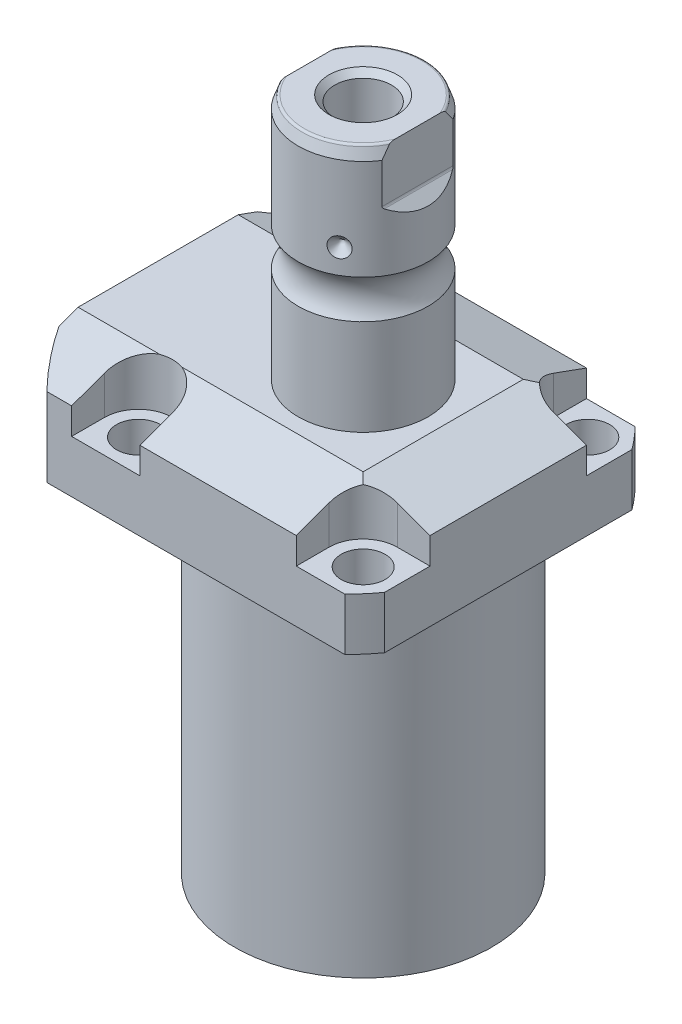
from build123d import *

# Parameters (mm, degrees)
SKETCH1_W                = 70.866
SKETCH1_H                = 85.496
EXTRUDE1_DEPTH           = 104.4448
SKETCH2_OUTSIDE_W        = 117.986
SKETCH2_OUTSIDE_H        = 103.356
SKETCH2_OUTSIDE_R        = 50.8
CUT_EXTRUDE1_DEPTH       = 105.4448
SKETCH3_W                = 45.1992
SKETCH3_H                = 79.4258
FILLET1_R                = 0.381
CUT_EXTRUDE2_DEPTH       = 12.243
CUT_EXTRUDE9_START       = -51.063
CUT_EXTRUDE9_DEPTH       = 87.496
CUT_EXTRUDE7_DEPTH       = 36.433
CUT_EXTRUDE7_DEPTH_BACK  = 36.433
SKETCH10_R               = 1.1811
SKETCH17_W               = 5.3594
SKETCH17_H               = 12.776
HOLE1_AT_2_COUNT         = 2
HOLE1_AT_2_PITCH         = 54.864
HOLE1_AT_3_COUNT         = 2
HOLE1_AT_3_PITCH         = 77.589412886
HOLE1_AT_4_COUNT         = 2
HOLE1_AT_4_PITCH         = 54.864
CHAMFER1_SIZE            = 0.635
FILLET2_R                = 0.635
CIRPATTERN1_COUNT        = 3
CUT_EXTRUDE10_DEPTH      = 36.433
CUT_EXTRUDE10_DEPTH_BACK = 36.433
CHAMFER2_SIZE            = 1.4351


with BuildPart() as part:
    # Sketch1 → Extrude1 (new body)
    with BuildSketch(Plane(origin=(0, 0, 0), x_dir=(0, 0, 1), z_dir=(0, -1, 0))):
        with Locations((0, 7.315)):
            Rectangle(SKETCH1_W, SKETCH1_H)
    extrude(amount=-EXTRUDE1_DEPTH)

    # Sketch2 outside → Cut-Extrude1 (cut, through all)
    with BuildSketch(Plane.XZ):
        with Locations((-7.315, 0)):
            Rectangle(SKETCH2_OUTSIDE_W, SKETCH2_OUTSIDE_H)
        with Locations((-5.4102, 0)):
            Circle(SKETCH2_OUTSIDE_R, mode=Mode.SUBTRACT)
    extrude(amount=-CUT_EXTRUDE1_DEPTH, mode=Mode.SUBTRACT)

    # Sketch3 → Cut-Revolve1 (revolve, cut)
    with BuildSketch(Plane(origin=(0, 0, 0), x_dir=(0, 0, -1), z_dir=(1, 0, 0))):
        with Locations((53.9941, 39.7129)):
            Rectangle(SKETCH3_W, SKETCH3_H)
    revolve(axis=Axis((0, -93.345, 0), (0, 1, 0)), mode=Mode.SUBTRACT)

    # Fillet1
    fillet1_edges = [part.edges().sort_by_distance(p)[0] for p in [
        (0, 79.4258, 31.3945),
    ]]
    fillet(fillet1_edges, radius=FILLET1_R)

    # Sketch4 → Cut-Extrude2 (cut)
    with BuildSketch(Plane(origin=(0, 104.4448, 0), x_dir=(-1, 0, 0), z_dir=(0, 1, 0))):
        with BuildLine():
            Line((-19.1008, -35.433), (-19.1008, -27.432))
            ThreePointArc((-19.1008, -27.432), (-21.540951985, -21.540951985), (-27.432, -19.1008))
            Line((-27.432, -19.1008), (-35.433, -19.1008))
            Line((-35.433, -19.1008), (-35.433, -35.433))
            Line((-35.433, -35.433), (-19.1008, -35.433))
        make_face()
        with BuildLine():
            Line((35.7632, -35.433), (19.1008, -35.433))
            Line((19.1008, -35.433), (19.1008, -27.432))
            ThreePointArc((19.1008, -27.432), (27.432, -19.1008), (35.7632, -27.432))
            Line((35.7632, -27.432), (35.7632, -35.433))
        make_face()
        with BuildLine():
            Line((19.1008, 35.433), (19.1008, 27.432))
            ThreePointArc((19.1008, 27.432), (27.432, 19.1008), (35.7632, 27.432))
            Line((35.7632, 27.432), (35.7632, 35.433))
            Line((35.7632, 35.433), (19.1008, 35.433))
        make_face()
        with BuildLine():
            Line((-27.432, 19.1008), (-35.433, 19.1008))
            Line((-35.433, 19.1008), (-35.433, 35.433))
            Line((-35.433, 35.433), (-19.1008, 35.433))
            Line((-19.1008, 35.433), (-19.1008, 27.432))
            ThreePointArc((-19.1008, 27.432), (-21.540951985, 21.540951985), (-27.432, 19.1008))
        make_face()
    extrude(amount=-CUT_EXTRUDE2_DEPTH, mode=Mode.SUBTRACT)

    # Sketch5 → Cut-Extrude9 (cut)
    with BuildSketch(Plane(origin=(0, 0, 0), x_dir=(0, 0, -1), z_dir=(1, 0, 0)).offset(CUT_EXTRUDE9_START)):
        Polygon((-19.558, 104.4448), (-35.433, 98.666772531), (-35.433, 104.4448), align=None)
    cut_extrude9 = extrude(amount=CUT_EXTRUDE9_DEPTH, mode=Mode.SUBTRACT)

    # Mirror1: Cut-Extrude9 across plane
    add(cut_extrude9.mirror(Plane.XY), mode=Mode.SUBTRACT)

    # Sketch9 → Cut-Extrude7 (cut, two sides)
    with BuildSketch(Plane.XY) as cut_extrude7_sk:
        Polygon((19.558, 104.4448), (35.433, 98.666772531), (35.433, 104.4448), align=None)
    extrude(amount=CUT_EXTRUDE7_DEPTH, mode=Mode.SUBTRACT)
    extrude(cut_extrude7_sk.sketch, amount=-CUT_EXTRUDE7_DEPTH_BACK, mode=Mode.SUBTRACT)

    # Sketch20 → Cut-Revolve4 (revolve, cut)
    with BuildSketch(Plane(origin=(-35.0774, 88.9, -18.1102), x_dir=(0, 1, 0), z_dir=(1, 0, 0)), mode=Mode.PRIVATE) as cut_revolve4_sk:
        Polygon((-9.4742, 38.3413), (-8.0264, 38.3413), (-8.0264, 35.8902), (-7.0104, 35.8902), (-7.0104, 33.8836), (3.9624, 33.8836), (3.9624, 32.639), (-9.4742, 32.639), align=None)
    cut_revolve4 = revolve(cut_revolve4_sk.sketch.rotate(Axis((-35.0774, 81.620304954, 14.5288), (0, 1, 0)), 180), axis=Axis((-35.0774, 81.620304954, 14.5288), (0, 1, 0)), mode=Mode.SUBTRACT)  # turned: the seam where the file's is

    # Mirror10: Cut-Revolve4 across plane
    add(cut_revolve4.mirror(Plane.XY), mode=Mode.SUBTRACT)

    # Sketch15 → Revolve3 (revolve)
    with BuildSketch(Plane(origin=(0, 0, 0), x_dir=(0, 0, -1), z_dir=(1, 0, 0)), mode=Mode.PRIVATE) as revolve3_sk:
        with BuildLine():
            Line((0, 104.4448), (15.875, 104.4448))
            Line((15.875, 104.4448), (15.875, 127.82970643))
            ThreePointArc((15.875, 127.82970643), (14.3256, 132.5368), (15.875, 137.24389357))
            Line((15.875, 137.24389357), (15.875, 161.72179416))
            Line((15.875, 161.72179416), (14.81184082, 164.6428))
            Line((14.81184082, 164.6428), (0, 164.6428))
            Line((0, 164.6428), (0, 104.4448))
        make_face()
    revolve(revolve3_sk.sketch.rotate(Axis((0, 250.290824608, 0), (0, -1, 0)), 180), axis=Axis((0, 250.290824608, 0), (0, -1, 0)))  # turned: the seam where the file's is

    # Sketch17 → Hole1 (revolve, cut)
    with BuildSketch(Plane(origin=(27.432, 92.2018, -27.432), x_dir=(0, 0, 1), z_dir=(1, 0, 0))):
        with Locations((2.6797, 6.388)):
            Rectangle(SKETCH17_W, SKETCH17_H)
    hole1 = revolve(axis=Axis((27.432, -17.7982, -27.432), (0, 1, 0)), mode=Mode.SUBTRACT)

    # Hole1 at 2: Hole1 ×2
    with Locations(*[(0, 0, i * HOLE1_AT_2_PITCH) for i in range(1, HOLE1_AT_2_COUNT)]):
        add(hole1, mode=Mode.SUBTRACT)

    # Hole1 at 3: Hole1 ×2
    with Locations(*[Vector(-0.707106781, 0, 0.707106781) * (i * HOLE1_AT_3_PITCH) for i in range(1, HOLE1_AT_3_COUNT)]):
        add(hole1, mode=Mode.SUBTRACT)

    # Hole1 at 4: Hole1 ×2
    with Locations(*[(-i * HOLE1_AT_4_PITCH, 0, 0) for i in range(1, HOLE1_AT_4_COUNT)]):
        add(hole1, mode=Mode.SUBTRACT)

    # Chamfer1
    chamfer1_edges = [part.edges().sort_by_distance(p)[0] for p in [
        (-35.0774, 81.8896, 15.7734),
        (-35.0774, 81.8896, -15.7734),
    ]]
    chamfer(chamfer1_edges, length=CHAMFER1_SIZE)

    # Sketch21 → Cut-Revolve5 (revolve, cut)
    with BuildSketch(Plane.XZ.offset(-91.9226)):
        Polygon((-50.063, -1.9304), (-49.809, -1.9304), (-49.809, -6.7564), (-47.2563, -7.440393904), (-46.695693904, -8.001), (-30.759, -8.001), (-30.759, -12.9794), (-50.063, -12.9794), align=None)
    cut_revolve5 = revolve(axis=Axis((-57.549532301, 91.9226, -12.9794), (1, 0, 0)), mode=Mode.SUBTRACT)

    # Mirror13: Cut-Revolve5 across plane
    add(cut_revolve5.mirror(Plane.XY), mode=Mode.SUBTRACT)

    # Fillet2
    fillet2_edges = [part.edges().sort_by_distance(p)[0] for p in [
        (0, 164.6428, -14.81184082),
    ]]
    fillet(fillet2_edges, radius=FILLET2_R)

    # Sketch26 → Cut-Revolve7 (revolve, cut)
    with BuildSketch(Plane.XY, mode=Mode.PRIVATE) as cut_revolve7_sk:
        Polygon((-15.875, 145.6178), (-13.462, 143.2048), (-15.875, 143.2048), align=None)
    cut_revolve7 = revolve(cut_revolve7_sk.sketch.rotate(Axis((-39.772000707, 143.2048, 0), (1, 0, 0)), 90), axis=Axis((-39.772000707, 143.2048, 0), (1, 0, 0)), mode=Mode.SUBTRACT)  # turned: the seam where the file's is

    # CirPattern1: Cut-Revolve7 ×3 about axis
    cirpattern1_axis = Axis((0, 250.290824608, 0), (0, 1, 0))
    for i in range(1, CIRPATTERN1_COUNT):
        add(cut_revolve7.rotate(cirpattern1_axis, i * 360 / CIRPATTERN1_COUNT), mode=Mode.SUBTRACT)

    # Sketch27 → Hole2 (revolve, cut)
    with BuildSketch(Plane(origin=(0, 164.6428, 0), x_dir=(0, 0, 1), z_dir=(1, 0, 0))):
        Polygon((0, 0), (0, 28.812118634), (6.9469, 24.638), (6.9469, 0), align=None)
    revolve(axis=Axis((0, 168.886999587, 0), (0, -1, 0)), mode=Mode.SUBTRACT)

    # Sketch29 → Cut-Extrude10 (cut, two sides)
    with BuildSketch(Plane.XY) as cut_extrude10_sk:
        with BuildLine():
            Line((13.284, 164.6428), (13.284, 151.9428))
            ThreePointArc((13.284, 151.9428), (13.342003912, 151.651194643), (13.507185078, 151.403983558))
            Line((13.507185078, 151.403983558), (16.332, 148.579168636))
            Line((16.332, 148.579168636), (16.332, 164.6428))
            Line((16.332, 164.6428), (13.284, 164.6428))
        make_face()
        with BuildLine():
            Line((-16.332, 164.6428), (-13.284, 164.6428))
            Line((-13.284, 164.6428), (-13.284, 151.9428))
            ThreePointArc((-13.284, 151.9428), (-13.342003912, 151.651194643), (-13.507185078, 151.403983558))
            Line((-13.507185078, 151.403983558), (-16.332, 148.579168636))
            Line((-16.332, 148.579168636), (-16.332, 164.6428))
        make_face()
    extrude(amount=CUT_EXTRUDE10_DEPTH, mode=Mode.SUBTRACT)
    extrude(cut_extrude10_sk.sketch, amount=-CUT_EXTRUDE10_DEPTH_BACK, mode=Mode.SUBTRACT)

    # Chamfer2
    chamfer2_edges = [part.edges().sort_by_distance(p)[0] for p in [
        (0, 164.6428, -6.9469),
    ]]
    chamfer(chamfer2_edges, length=CHAMFER2_SIZE)


with BuildPart() as body_2:
    # Sketch10 → Revolve4 (revolve)
    with BuildSketch(Plane(origin=(-35.0774, 88.9, -18.1102), x_dir=(0, 1, 0), z_dir=(1, 0, 0))):
        with Locations((-9.2075, 8.1026)):
            Circle(SKETCH10_R)
    revolve(axis=Axis((-35.0774, 87.86749, -14.5288), (0, 1, 0)))


with BuildPart() as body_3:
    # Mirror12: mirrored copy
    add(body_2.part.mirror(Plane.XY))


solid = Compound([part.part, body_2.part, body_3.part])
